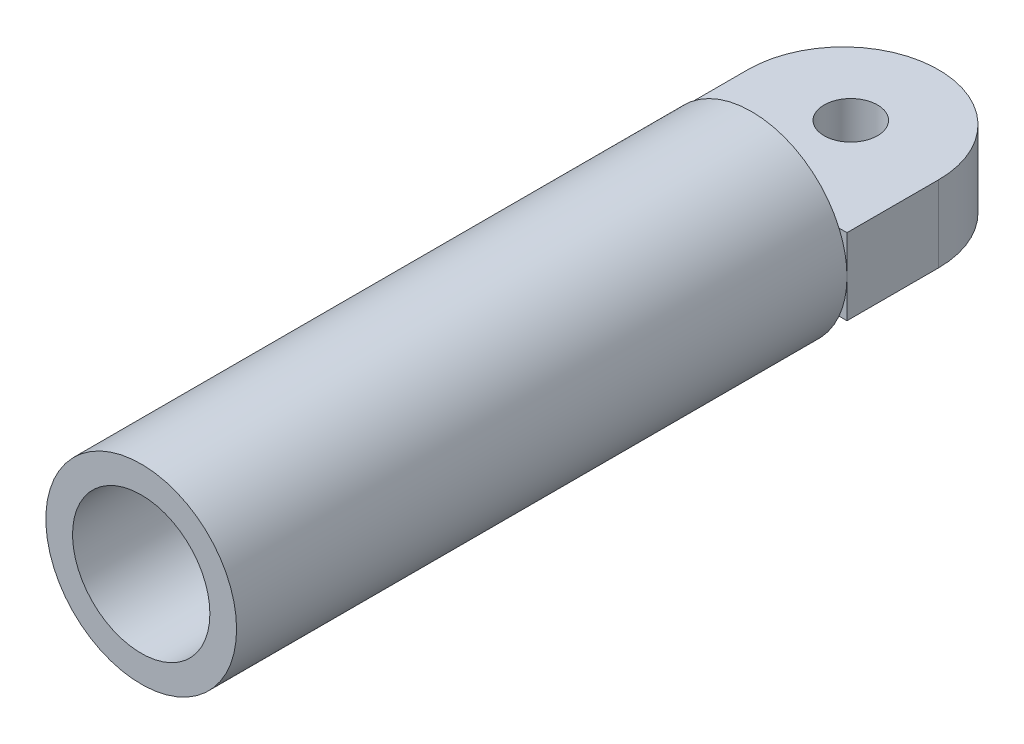
from build123d import *

# Parameters (mm, degrees)
SKETCH1_R           = 12.5
SKETCH1_R_2         = 9
BOSS_EXTRUDE1_DEPTH = 80
SKETCH2_R           = 3.5
BOSS_EXTRUDE2_DEPTH = 5


with BuildPart() as part:
    # Sketch1 → Boss-Extrude1 (new body)
    with BuildSketch(Plane.XY):
        Circle(SKETCH1_R)
        Circle(SKETCH1_R_2, mode=Mode.SUBTRACT)
    extrude(amount=BOSS_EXTRUDE1_DEPTH)

    # Sketch2 → Boss-Extrude2 (add, symmetric)
    with BuildSketch(Plane(origin=(0, 0, 0), x_dir=(1, 0, 0), z_dir=(0, 1, 0))):
        with BuildLine():
            Line((-12.5, 0), (12.5, 0))
            Line((12.5, 0), (12.5, 12))
            ThreePointArc((12.5, 12), (0, 24.5), (-12.5, 12))
            Line((-12.5, 12), (-12.5, 0))
        make_face()
        with Locations((0, 13)):
            Circle(SKETCH2_R, mode=Mode.SUBTRACT)
    extrude(amount=BOSS_EXTRUDE2_DEPTH, both=True)


solid = part.part
